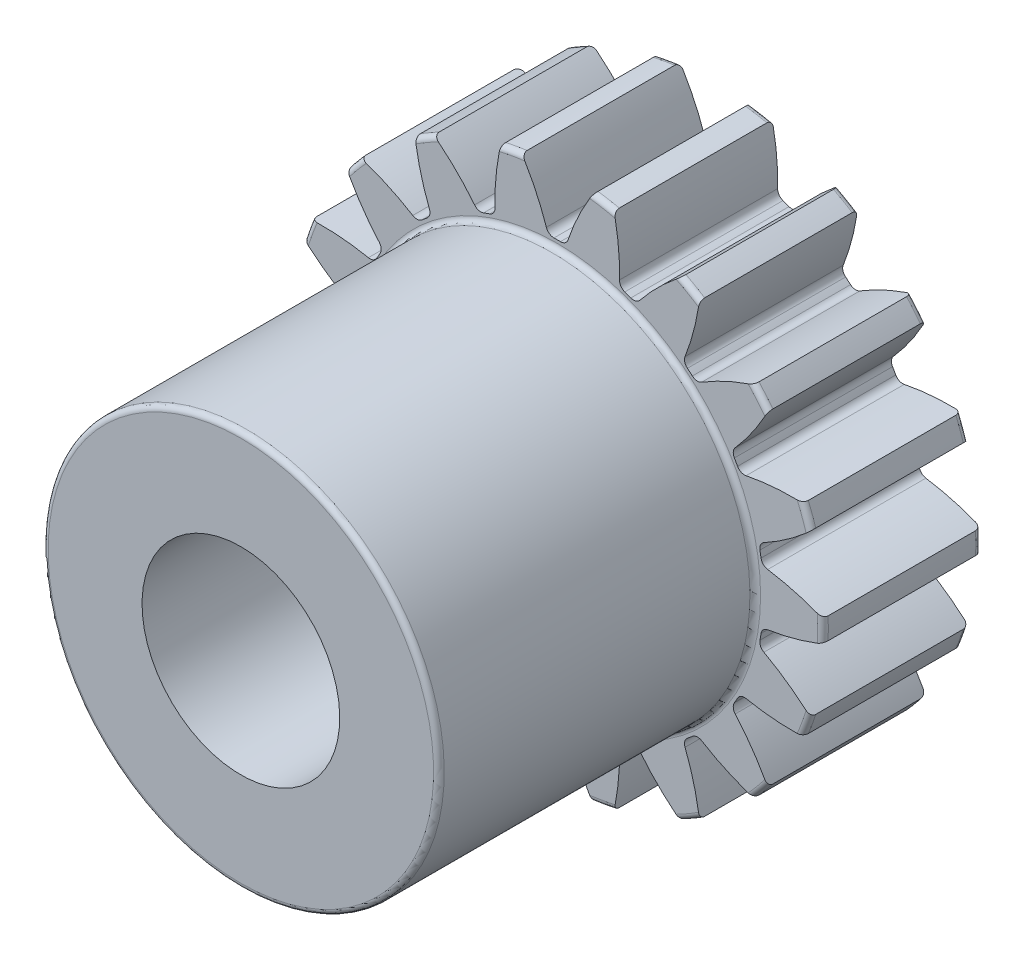
from build123d import *

# Parameters (mm, degrees)
FILLET2_R          = 0.10668
CUT_EXTRUDE2_DEPTH = 4.175
CIRPATTERN1_COUNT  = 18


with BuildPart() as part:
    # Sketch4 → Revolve1 (revolve)
    with BuildSketch(Plane(origin=(0, 0, 0), x_dir=(0, 0, -1), z_dir=(1, 0, 0))):
        Polygon((-9.525, 1.984375), (-9.525, 3.9751), (-3.175, 3.9751), (-3.175, 5.334), (0, 5.334), (0, 1.984375), align=None)
    revolve(axis=Axis((0, 0, 3.175), (0, 0, 1)))

    # Fillet2
    fillet2_edges = [part.edges().sort_by_distance(p)[0] for p in [
        (0, -5.334, 0),
        (0, -5.334, 3.175),
        (0, -3.9751, 3.175),
        (0, -3.9751, 9.525),
    ]]
    fillet(fillet2_edges, radius=FILLET2_R)

    # Sketch7 → Cut-Extrude2 (cut, through all)
    with BuildSketch(Plane.XY.offset(3.175)):
        with BuildLine():
            ThreePointArc((-0.064763188, 4.142868827), (0, 4.143375), (0.064763188, 4.142868827))
            ThreePointArc((0.064763188, 4.142868827), (0.158874403, 4.171960564), (0.217710969, 4.250963782))
            ThreePointArc((0.217710969, 4.250963782), (0.433564361, 4.783553385), (0.711994388, 5.286267113))
            ThreePointArc((0.711994388, 5.286267113), (0, 5.334), (-0.711994388, 5.286267113))
            ThreePointArc((-0.711994388, 5.286267113), (-0.433564361, 4.783553385), (-0.217710969, 4.250963782))
            ThreePointArc((-0.217710969, 4.250963782), (-0.158874403, 4.171960564), (-0.064763188, 4.142868827))
        make_face()
    cut_extrude2 = extrude(amount=-CUT_EXTRUDE2_DEPTH, mode=Mode.SUBTRACT)

    # CirPattern1: Cut-Extrude2 ×18 about axis
    cirpattern1_axis = Axis((0, 0, 0), (0, 0, 1))
    for i in range(1, CIRPATTERN1_COUNT):
        add(cut_extrude2.rotate(cirpattern1_axis, i * 360 / CIRPATTERN1_COUNT), mode=Mode.SUBTRACT)


solid = part.part
